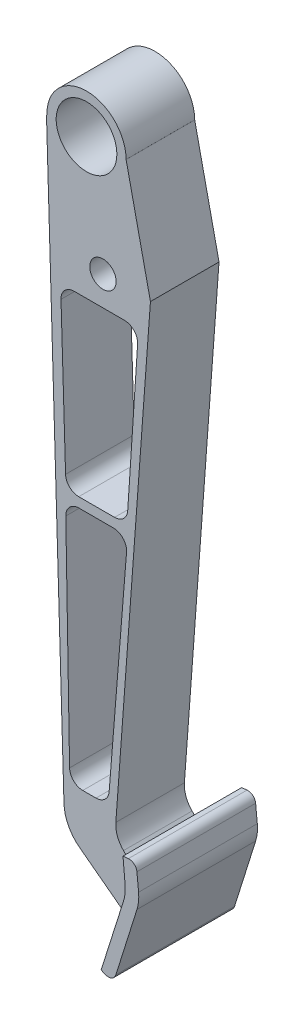
from build123d import *

# Parameters (mm, degrees)
SKETCH1_R                = 5
BOSS_EXTRUDE2_DEPTH      = 26
SKETCH9_R                = 11.5
CUT_EXTRUDE7_DEPTH       = 26
CUT_EXTRUDE8_DEPTH       = 57
BOSS_EXTRUDE5_DEPTH      = 35
BOSS_EXTRUDE5_DEPTH_BACK = 10


with BuildPart() as part:
    # Sketch1 → Boss-Extrude2 (new body)
    with BuildSketch(Plane.XY):
        with BuildLine():
            Line((-13.871543988, -187.456565175), (-0.750718318, -9.931237526))
            Line((-0.750718318, -9.931237526), (-9.971378105, 32.063387678))
            Line((-9.971378105, 32.063387678), (-9.97665526, 32.075234554))
            Line((-9.97665526, 32.075234554), (-9.977087782, 32.075348974))
            Line((-9.977087782, 32.075348974), (-9.978230603, 32.075651298))
            Line((-9.978230603, 32.075651298), (-9.977087779, 32.075655544))
            ThreePointArc((-9.977087779, 32.075655544), (-24.981119404, 47.075655002), (-39.977085612, 32.067592296))
            Line((-39.977085612, 32.067592296), (-40.143970803, 31.267359869))
            Line((-40.143970803, 31.267359869), (-33.520138903, -191.065133081))
            ThreePointArc((-33.520138903, -191.065133081), (-31.855635546, -197.51068285), (-27.565830072, -202.601188939))
            Line((-27.565830072, -202.601188939), (-6.826859709, -218.262215052))
            Line((-6.826859709, -218.262215052), (-2.296825809, -203.937706242))
            Line((-2.296825809, -203.937706242), (-10.96981355, -195.264718501))
            ThreePointArc((-10.96981355, -195.264718501), (-13.272387355, -191.677160819), (-13.871543988, -187.456565175))
        make_face()
        with Locations((-18.750718318, -9.924344456)):
            Circle(SKETCH1_R, mode=Mode.SUBTRACT)
    extrude(amount=BOSS_EXTRUDE2_DEPTH)

    # Sketch9 → Cut-Extrude7 (cut)
    with BuildSketch(Plane.XY):
        with Locations((-24.977087779, 32.075655544)):
            Circle(SKETCH9_R)
    extrude(amount=CUT_EXTRUDE7_DEPTH, mode=Mode.SUBTRACT)

    # Sketch10 → Cut-Extrude8 (cut)
    with BuildSketch(Plane.XY):
        with BuildLine():
            Line((-29.654511548, -21.002260091), (-10.602832717, -21.002260091))
            ThreePointArc((-10.602832717, -21.002260091), (-6.952180176, -22.585721488), (-5.613794584, -26.333165681))
            Line((-5.613794584, -26.333165681), (-9.366001824, -82.90490561))
            ThreePointArc((-9.366001824, -82.90490561), (-10.938501354, -86.224652561), (-14.355039957, -87.574000019))
            Line((-14.355039957, -87.574000019), (-27.922723591, -87.574000019))
            ThreePointArc((-27.922723591, -87.574000019), (-31.403747307, -86.163216354), (-32.920382463, -82.726989577))
            Line((-32.920382463, -82.726989577), (-34.65217042, -26.155249648))
            ThreePointArc((-34.65217042, -26.155249648), (-33.243727882, -22.521236375), (-29.654511548, -21.002260091))
        make_face()
        with BuildLine():
            Line((-14.784895538, -91.270958439), (-27.832276958, -91.270958439))
            ThreePointArc((-27.832276958, -91.270958439), (-31.398552804, -92.766436134), (-32.831514258, -96.358287804))
            Line((-32.831514258, -96.358287804), (-31.399590979, -178.329847134))
            ThreePointArc((-31.399590979, -178.329847134), (-29.904875984, -181.808793615), (-26.400353679, -183.242517768))
            Line((-26.400353679, -183.242517768), (-21.386933453, -183.242517768))
            ThreePointArc((-21.386933453, -183.242517768), (-17.996285711, -181.917229715), (-16.403071948, -178.643920925))
            Line((-16.403071948, -178.643920925), (-9.801034032, -96.672361595))
            ThreePointArc((-9.801034032, -96.672361595), (-11.110183591, -92.880310697), (-14.784895538, -91.270958439))
        make_face()
    extrude(amount=CUT_EXTRUDE8_DEPTH, mode=Mode.SUBTRACT)

    # Sketch11 → Boss-Extrude5 (add, two sides)
    with BuildSketch(Plane.XY) as boss_extrude5_sk:
        with BuildLine():
            Line((-2.296825809, -203.937706242), (-6.826859709, -218.262215052))
            Line((-6.826859709, -218.262215052), (-10.445160296, -229.703714118))
            Line((-10.445160296, -229.703714118), (-8.916301823, -230.367275492))
            ThreePointArc((-8.916301823, -230.367275492), (-6.475373676, -230.344079521), (-4.859724836, -228.514230593))
            Line((-4.859724836, -228.514230593), (3.138639896, -203.047724737))
            ThreePointArc((3.138639896, -203.047724737), (3.748708228, -200.0920804), (3.754779808, -197.074137401))
            Line((3.754779808, -197.074137401), (3.121631235, -190.683812553))
            ThreePointArc((3.121631235, -190.683812553), (2.049929764, -188.669228662), (-0.128962116, -187.991347795))
            Line((-0.128962116, -187.991347795), (-2.151569065, -188.170856397))
            Line((-2.151569065, -188.170856397), (-1.355950129, -197.135465185))
            ThreePointArc((-1.355950129, -197.135465185), (-1.386055005, -200.091588206), (-1.995347326, -202.984395233))
            Line((-1.995347326, -202.984395233), (-2.296825809, -203.937706242))
        make_face()
    extrude(amount=BOSS_EXTRUDE5_DEPTH)
    extrude(boss_extrude5_sk.sketch, amount=-BOSS_EXTRUDE5_DEPTH_BACK)


solid = part.part
